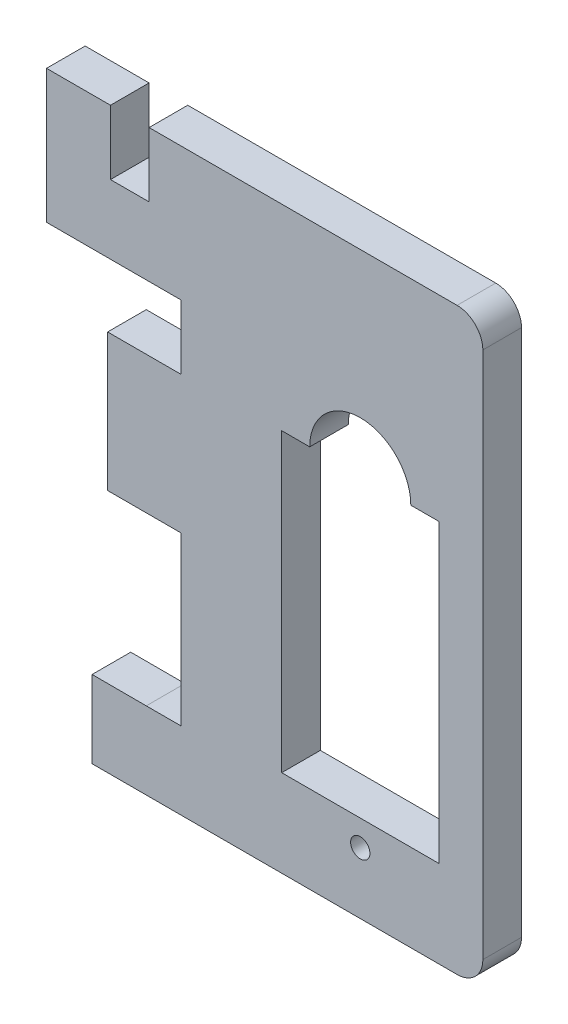
from build123d import *

# Parameters (mm, degrees)
BOSS_EXTRUDE1_DEPTH = 3
SKETCH2_W           = 12.2
SKETCH2_H           = 23
CUT_EXTRUDE1_DEPTH  = 4
SKETCH5_R           = 3.925
SKETCH5_R_2         = 0.75
CUT_EXTRUDE2_DEPTH  = 3


with BuildPart() as part:
    # Sketch1 → Boss-Extrude1 (new body)
    with BuildSketch(Plane.XY):
        with BuildLine():
            Line((-29.761795946, -16.735008518), (-29.761795946, -27.401277683))
            Line((-29.761795946, -27.401277683), (-24.065046346, -27.401277683))
            Line((-24.065046346, -27.401277683), (-24.065046346, -40.380088331))
            Line((-24.065046346, -40.380088331), (-26.761795946, -40.380088331))
            Line((-26.761795946, -40.380088331), (-30.96655582, -40.372207157))
            Line((-30.96655582, -40.372207157), (-30.96655582, -46.377768313))
            Line((-30.96655582, -46.377768313), (-27.761795946, -46.377768313))
            Line((-27.761795946, -46.377768313), (-2.624484573, -46.377768313))
            ThreePointArc((-2.624484573, -46.377768313), (-1.210271011, -45.791981876), (-0.624484573, -44.377768313))
            Line((-0.624484573, -44.377768313), (-0.624484573, -3.377768313))
            ThreePointArc((-0.624484573, -3.377768313), (-1.210271011, -1.963554751), (-2.624484573, -1.377768313))
            Line((-2.624484573, -1.377768313), (-26.540138154, -1.377768313))
            Line((-26.540138154, -1.377768313), (-26.540138154, -6.377768313))
            Line((-26.540138154, -6.377768313), (-29.540138154, -6.377768313))
            Line((-29.540138154, -6.377768313), (-29.540138154, -1.377768313))
            Line((-29.540138154, -1.377768313), (-34.506351605, -1.377768313))
            Line((-34.506351605, -1.377768313), (-34.506351605, -11.735008518))
            Line((-34.506351605, -11.735008518), (-29.761795946, -11.735008518))
            Line((-29.761795946, -11.735008518), (-24.065046346, -11.735008518))
            Line((-24.065046346, -11.735008518), (-24.065046346, -16.735008518))
            Line((-24.065046346, -16.735008518), (-29.761795946, -16.735008518))
        make_face()
    extrude(amount=BOSS_EXTRUDE1_DEPTH)

    # Sketch2 → Cut-Extrude1 (cut, through all)
    with BuildSketch(Plane.XY.offset(3)):
        with Locations((-10.143120504, -28.115803741)):
            Rectangle(SKETCH2_W, SKETCH2_H)
    extrude(amount=-CUT_EXTRUDE1_DEPTH, mode=Mode.SUBTRACT)

    # Sketch5 → Cut-Extrude2 (cut)
    with BuildSketch(Plane.XY.offset(3)):
        with Locations((-10.143120504, -16.615803741)):
            Circle(SKETCH5_R)
        with Locations((-10.143120504, -41.615803741)):
            Circle(SKETCH5_R_2)
    extrude(amount=-CUT_EXTRUDE2_DEPTH, mode=Mode.SUBTRACT)


solid = part.part
